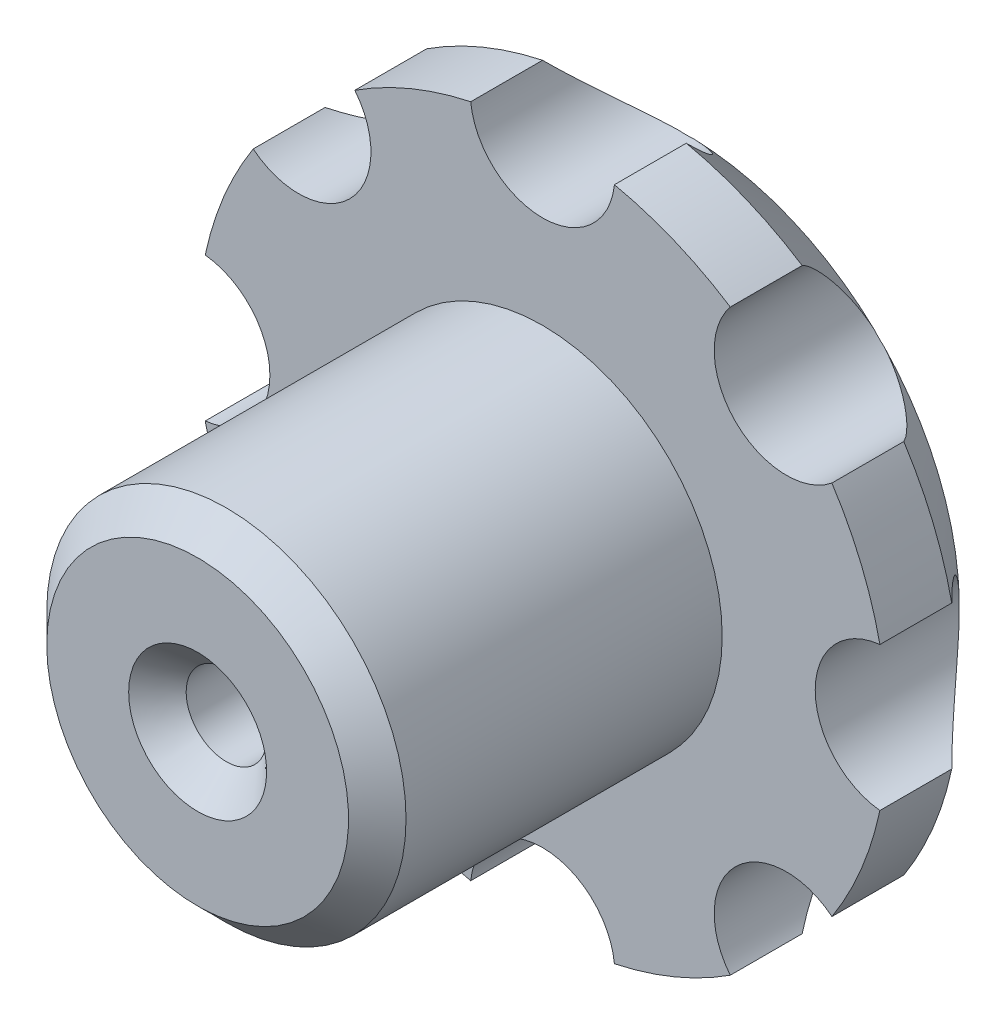
from build123d import *

# Parameters (mm, degrees)
SCHNITT_LINEAR_AUSTRAGEN1_DEPTH = 49.041648598
KREISMUSTER1_COUNT              = 8
SKIZZE3_W                       = 2.8
SKIZZE3_H                       = 29.5
FASE1_SIZE                      = 2


with BuildPart() as part:
    # Skizze1 → Rotation1 (revolve)
    with BuildSketch(Plane(origin=(0, 0, 0), x_dir=(1, 0, 0), z_dir=(0, 1, 0))):
        Polygon((0, 0), (-19, 0), (-24, -5), (-24, -10), (-12.5, -10), (-12.5, -34), (0, -34), align=None)
    revolve(axis=Axis((0, 0, 34), (0, 0, -1)))

    # Skizze2 → Schnitt-Linear austragen1 (cut, through all)
    with BuildSketch(Plane.XY):
        with BuildLine():
            ThreePointArc((-5, 23.473389189), (0, 18.972344588), (5, 23.473389189))
            ThreePointArc((5, 23.473389189), (0, 24), (-5, 23.473389189))
        make_face()
    schnitt_linear_austragen1 = extrude(amount=SCHNITT_LINEAR_AUSTRAGEN1_DEPTH, mode=Mode.SUBTRACT)

    # Kreismuster1: Schnitt-Linear austragen1 ×8 about axis
    kreismuster1_axis = Axis((0, 0, -88.99), (0, 0, 1))
    for i in range(1, KREISMUSTER1_COUNT):
        add(schnitt_linear_austragen1.rotate(kreismuster1_axis, i * 360 / KREISMUSTER1_COUNT), mode=Mode.SUBTRACT)

    # Skizze3 → Schnitt-Rotation1 (revolve, cut)
    with BuildSketch(Plane(origin=(0, 0, 0), x_dir=(1, 0, 0), z_dir=(0, 1, 0))):
        Polygon((0, 0), (0, -2.5), (-2.5, 0), align=None)
        with Locations((-1.4, -19.25)):
            Rectangle(SKIZZE3_W, SKIZZE3_H)
    revolve(axis=Axis((0, 0, 0), (0, 0, 1)), mode=Mode.SUBTRACT)

    # Fase1
    fase1_edges = [part.edges().sort_by_distance(p)[0] for p in [
        (12.5, 0, 34),
        (2.8, 0, 34),
    ]]
    chamfer(fase1_edges, length=FASE1_SIZE)


solid = part.part
